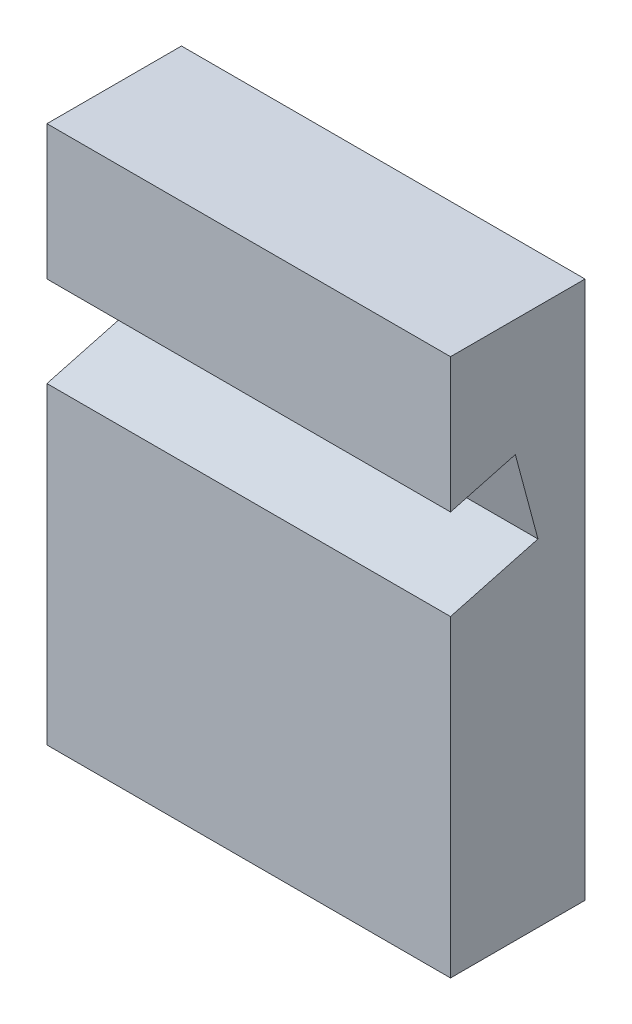
from build123d import *

# Parameters (mm, degrees)
BOSS_EXTRUDE1_DEPTH = 60


with BuildPart() as part:
    # Sketch1 → Boss-Extrude1 (new body)
    with BuildSketch(Plane.YZ):
        Polygon((0, 0), (80, 0), (80, 20), (60, 20), (62.581784898, 10.364647586), (50.024749156, 7), (46.541409655, 20), (0, 20), align=None)
    extrude(amount=BOSS_EXTRUDE1_DEPTH)


solid = part.part
